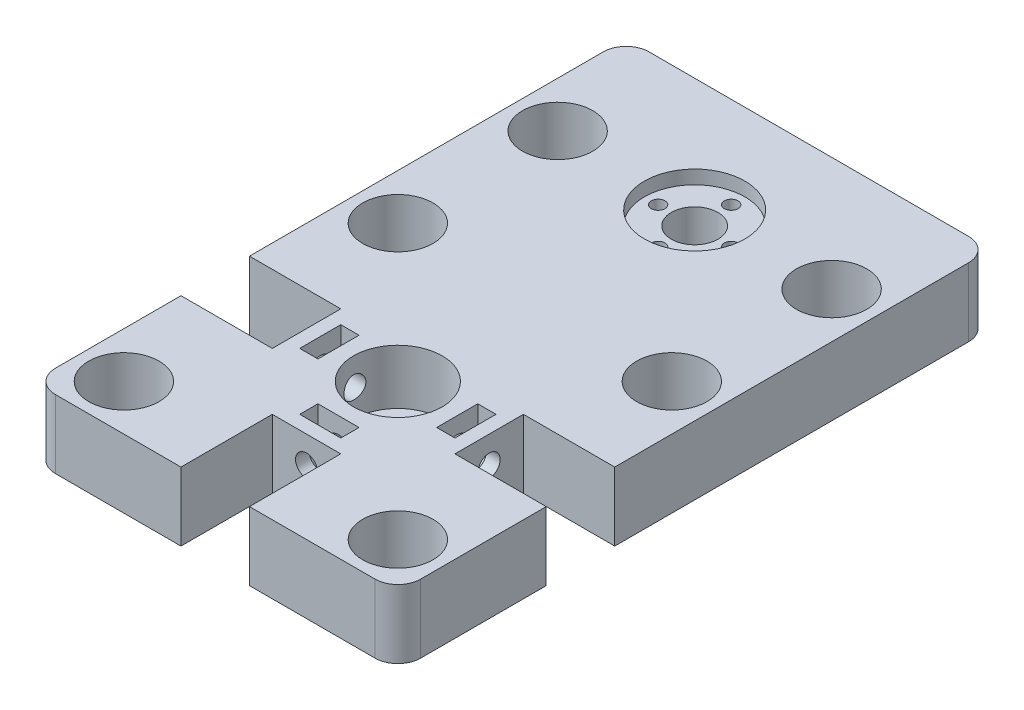
from build123d import *

# Parameters (mm, degrees)
ESBO_O1_W                = 80
ESBO_O1_H                = 130
RESSALTO_EXTRUS_O1_DEPTH = 15
ESBO_O2_R                = 7.7
CORTE_EXTRUS_O1_DEPTH    = 16
ESBO_O3_R                = 9.7
CORTE_EXTRUS_O2_DEPTH    = 12
ESBO_O4_R                = 4.6
CORTE_EXTRUS_O3_DEPTH    = 4
ESBO_O5_W                = 15
ESBO_O5_H                = 20
ESBO_O5_W_2              = 20
ESBO_O5_H_2              = 15
CORTE_EXTRUS_O4_DEPTH    = 16
ESBO_O6_R                = 2.4
CORTE_EXTRUS_O5_DEPTH    = 15
ESBO_O7_R                = 2.4
CORTE_EXTRUS_O6_DEPTH    = 15
ESBO_O8_R                = 11
CORTE_EXTRUS_O7_DEPTH    = 3
ESBO_O10_R               = 5.1
ESBO_O10_R_2             = 1.5
CORTE_EXTRUS_O9_DEPTH    = 13
FILETE1_R                = 5
FILETE2_R                = 5
ESBO_O11_R               = 2.4
CORTE_EXTRUS_O10_DEPTH   = 15
CORTE_EXTRUS_O11_DEPTH   = 4
CORTE_EXTRUS_O12_DEPTH   = 4
CORTE_EXTRUS_O13_DEPTH   = 4


with BuildPart() as part:
    # Esboço1 → Ressalto-extrusão1 (new body)
    with BuildSketch(Plane(origin=(0, 0, 0), x_dir=(1, 0, 0), z_dir=(0, 1, 0))):
        Rectangle(ESBO_O1_W, ESBO_O1_H)
    extrude(amount=RESSALTO_EXTRUS_O1_DEPTH)

    # Esboço2 → Corte-extrusão1 (cut, through all)
    with BuildSketch(Plane(origin=(0, 15, 0), x_dir=(1, 0, 0), z_dir=(0, 1, 0))):
        with Locations((-30, 5)):
            Circle(ESBO_O2_R)
        with Locations((30, 5)):
            Circle(ESBO_O2_R)
        with Locations((-30, -55)):
            Circle(ESBO_O2_R)
        with Locations((30, -55)):
            Circle(ESBO_O2_R)
        with Locations((-30, 40)):
            Circle(ESBO_O2_R)
        with Locations((30, 40)):
            Circle(ESBO_O2_R)
    extrude(amount=-CORTE_EXTRUS_O1_DEPTH, mode=Mode.SUBTRACT)

    # Esboço3 → Corte-extrusão2 (cut)
    with BuildSketch(Plane(origin=(0, 15, 0), x_dir=(1, 0, 0), z_dir=(0, 1, 0))):
        with Locations((0, -25)):
            Circle(ESBO_O3_R)
    extrude(amount=-CORTE_EXTRUS_O2_DEPTH, mode=Mode.SUBTRACT)

    # Esboço4 → Corte-extrusão3 (cut, through all)
    with BuildSketch(Plane(origin=(0, 3, 0), x_dir=(1, 0, 0), z_dir=(0, 1, 0))):
        with Locations((0, -25)):
            Circle(ESBO_O4_R)
    extrude(amount=-CORTE_EXTRUS_O3_DEPTH, mode=Mode.SUBTRACT)

    # Esboço5 → Corte-extrusão4 (cut, through all)
    with BuildSketch(Plane(origin=(0, 15, 0), x_dir=(1, 0, 0), z_dir=(0, 1, 0))):
        with Locations((0, -55)):
            Rectangle(ESBO_O5_W, ESBO_O5_H)
        with Locations((30, -25)):
            Rectangle(ESBO_O5_W_2, ESBO_O5_H_2)
        with Locations((-30, -25)):
            Rectangle(ESBO_O5_W_2, ESBO_O5_H_2)
    extrude(amount=-CORTE_EXTRUS_O4_DEPTH, mode=Mode.SUBTRACT)

    # Esboço6 → Corte-extrusão5 (cut)
    with BuildSketch(Plane.XY.offset(45)):
        with Locations((0, 9)):
            Circle(ESBO_O6_R)
    extrude(amount=-CORTE_EXTRUS_O5_DEPTH, mode=Mode.SUBTRACT)

    # Esboço7 → Corte-extrusão6 (cut)
    with BuildSketch(Plane(origin=(20, 0, 0), x_dir=(0, 0, -1), z_dir=(1, 0, 0))):
        with Locations((-25, 9)):
            Circle(ESBO_O7_R)
    extrude(amount=-CORTE_EXTRUS_O6_DEPTH, mode=Mode.SUBTRACT)

    # Esboço8 → Corte-extrusão7 (cut)
    with BuildSketch(Plane(origin=(0, 15, 0), x_dir=(1, 0, 0), z_dir=(0, 1, 0))):
        with Locations((0, 40)):
            Circle(ESBO_O8_R)
    extrude(amount=-CORTE_EXTRUS_O7_DEPTH, mode=Mode.SUBTRACT)

    # Esboço10 → Corte-extrusão9 (cut, through all)
    with BuildSketch(Plane(origin=(0, 12, 0), x_dir=(1, 0, 0), z_dir=(0, 1, 0))):
        with Locations((0, 40)):
            Circle(ESBO_O10_R)
        with Locations((0, 48)):
            Circle(ESBO_O10_R_2)
        with Locations((8, 40)):
            Circle(ESBO_O10_R_2)
        with Locations((0, 32)):
            Circle(ESBO_O10_R_2)
        with Locations((-8, 40)):
            Circle(ESBO_O10_R_2)
    extrude(amount=-CORTE_EXTRUS_O9_DEPTH, mode=Mode.SUBTRACT)

    # Filete1
    filete1_edges = [part.edges().sort_by_distance(p)[0] for p in [
        (-40, 7.5, -65),
        (40, 7.5, -65),
    ]]
    fillet(filete1_edges, radius=FILETE1_R)

    # Filete2
    filete2_edges = [part.edges().sort_by_distance(p)[0] for p in [
        (40, 7.5, 65),
        (-40, 7.5, 65),
    ]]
    fillet(filete2_edges, radius=FILETE2_R)

    # Esboço11 → Corte-extrusão10 (cut)
    with BuildSketch(Plane.ZY.offset(20)):
        with Locations((25, 9)):
            Circle(ESBO_O11_R)
    extrude(amount=-CORTE_EXTRUS_O10_DEPTH, mode=Mode.SUBTRACT)

    # Esboço12 → Corte-extrusão11 (cut)
    with BuildSketch(Plane.ZY.offset(17)):
        Polygon((22.75, 5.102885683), (27.25, 5.102885683), (29.5, 9), (29.5, 15), (20.5, 15), (20.5, 9), align=None)
    extrude(amount=-CORTE_EXTRUS_O11_DEPTH, mode=Mode.SUBTRACT)

    # Esboço13 → Corte-extrusão12 (cut)
    with BuildSketch(Plane.XY.offset(42)):
        Polygon((-2.25, 5.102885683), (2.25, 5.102885683), (4.5, 9), (4.5, 15), (-4.5, 15), (-4.5, 9), align=None)
    extrude(amount=-CORTE_EXTRUS_O12_DEPTH, mode=Mode.SUBTRACT)

    # Esboço14 → Corte-extrusão13 (cut)
    with BuildSketch(Plane(origin=(17, 0, 0), x_dir=(0, 0, -1), z_dir=(1, 0, 0))):
        Polygon((-27.25, 5.102885683), (-22.75, 5.102885683), (-20.5, 9), (-20.5, 15), (-29.5, 15), (-29.5, 9), align=None)
    extrude(amount=-CORTE_EXTRUS_O13_DEPTH, mode=Mode.SUBTRACT)


solid = part.part
